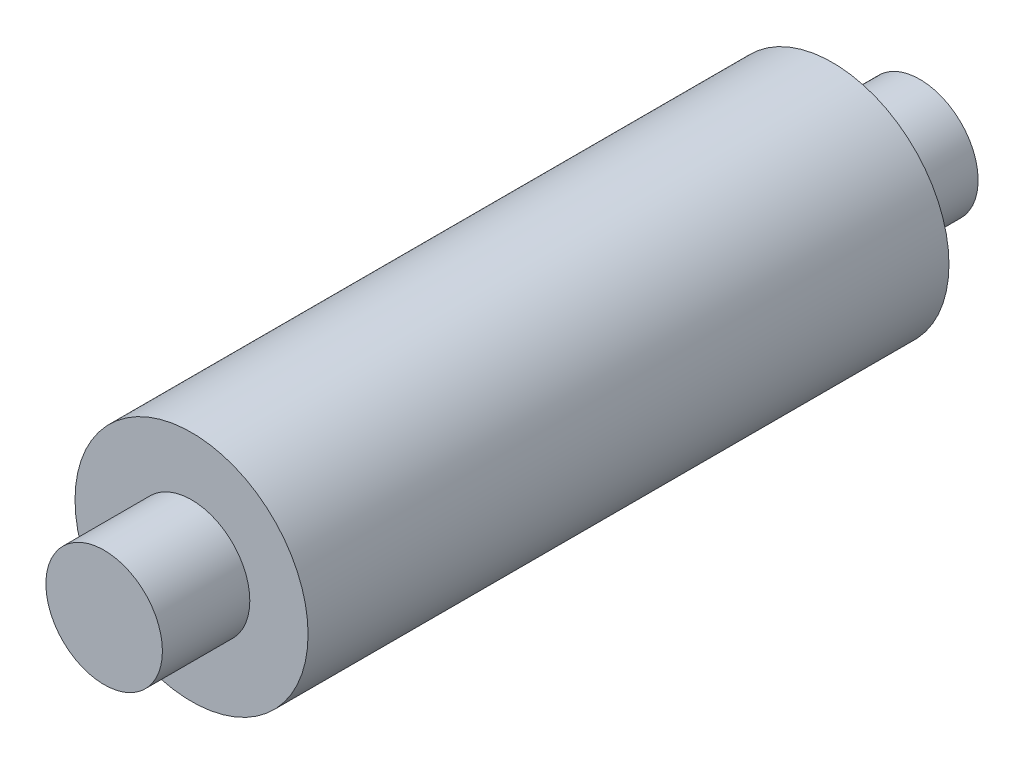
from build123d import *

# Parameters (mm, degrees)
SKETCH_1_R      = 2
EXTRUDE_1_DEPTH = 11
SKETCH_2_R      = 1
EXTRUDE_2_DEPTH = 1.5
SKETCH_3_R      = 1
EXTRUDE_3_DEPTH = 1.5


with BuildPart() as part:
    # 草图1 → 凸台-拉伸1 (new body)
    with BuildSketch(Plane.XY):
        Circle(SKETCH_1_R)
    extrude(amount=EXTRUDE_1_DEPTH)

    # 草图2 → 凸台-拉伸2 (add)
    with BuildSketch(Plane.XY.offset(11)):
        Circle(SKETCH_2_R)
    extrude(amount=EXTRUDE_2_DEPTH)

    # 草图3 → 凸台-拉伸3 (add)
    with BuildSketch(Plane(origin=(0, 0, 0), x_dir=(-1, 0, 0), z_dir=(0, 0, -1))):
        Circle(SKETCH_3_R)
    extrude(amount=EXTRUDE_3_DEPTH)


solid = part.part
